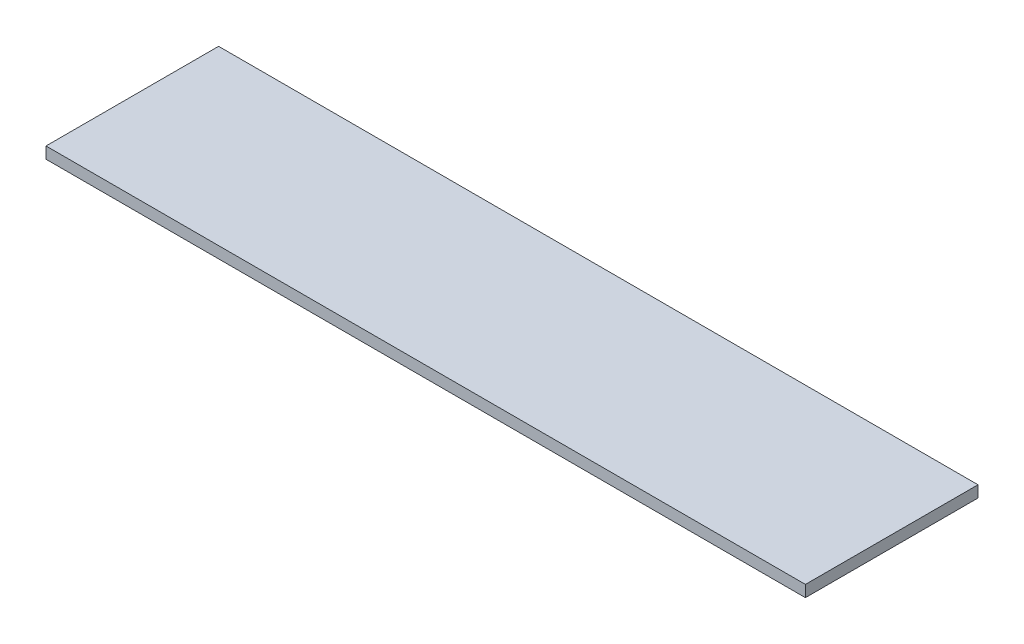
from build123d import *

# Parameters (mm, degrees)
SKETCH1_W           = 104.775
SKETCH1_H           = 23.8125
BOSS_EXTRUDE1_DEPTH = 1.5875


with BuildPart() as part:
    # Sketch1 → Boss-Extrude1 (new body)
    with BuildSketch(Plane(origin=(0, 0, 0), x_dir=(1, 0, 0), z_dir=(0, 1, 0))):
        Rectangle(SKETCH1_W, SKETCH1_H)
    extrude(amount=BOSS_EXTRUDE1_DEPTH)


solid = part.part
